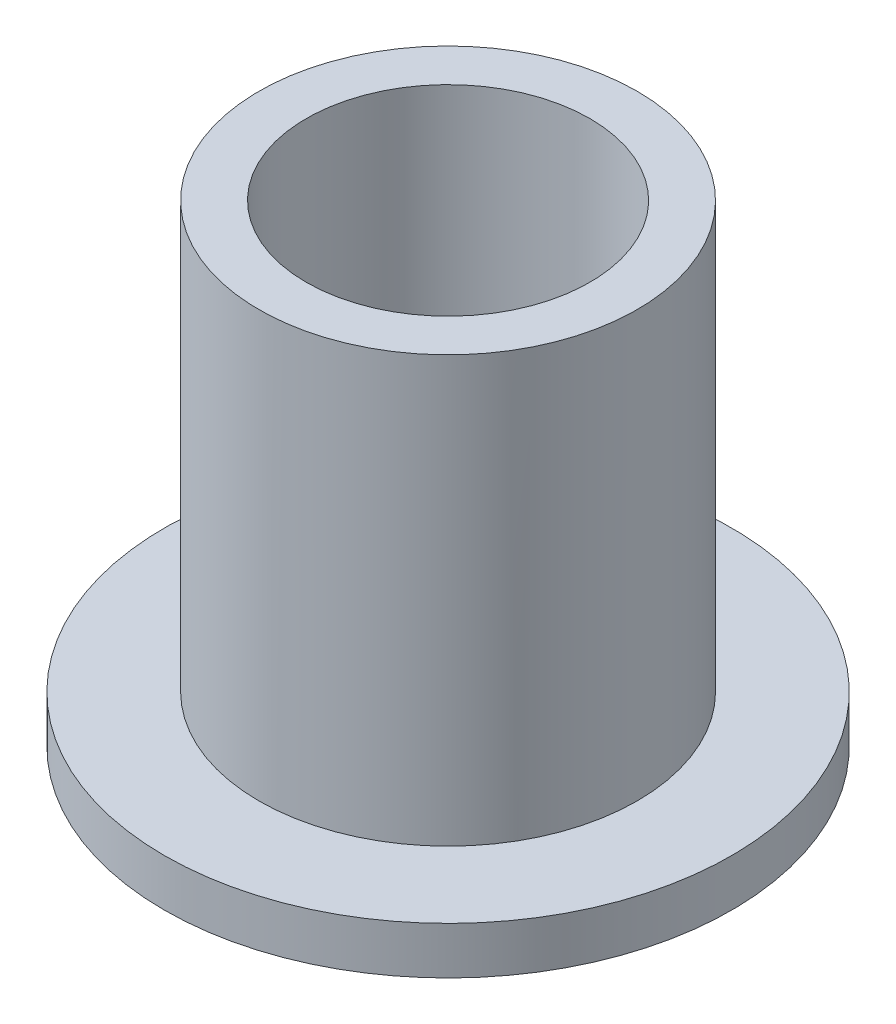
from build123d import *

# Parameters (mm, degrees)
SKETCH5_W           = 1
SKETCH5_H           = 10
SKETCH3_R           = 6
SKETCH3_R_2         = 4
BOSS_EXTRUDE2_DEPTH = 1


with BuildPart() as part:
    # Sketch5 → Revolve1 (revolve)
    with BuildSketch(Plane(origin=(0, 0, 0), x_dir=(0, 0, -1), z_dir=(1, 0, 0))):
        with Locations((3.5, 5)):
            Rectangle(SKETCH5_W, SKETCH5_H)
    revolve(axis=Axis((0, 0, 0), (0, 1, 0)))

    # Sketch3 → Boss-Extrude2 (add)
    with BuildSketch(Plane(origin=(0, 0, 0), x_dir=(1, 0, 0), z_dir=(0, 1, 0))):
        Circle(SKETCH3_R)
        Circle(SKETCH3_R_2, mode=Mode.SUBTRACT)
    extrude(amount=BOSS_EXTRUDE2_DEPTH)


solid = part.part
